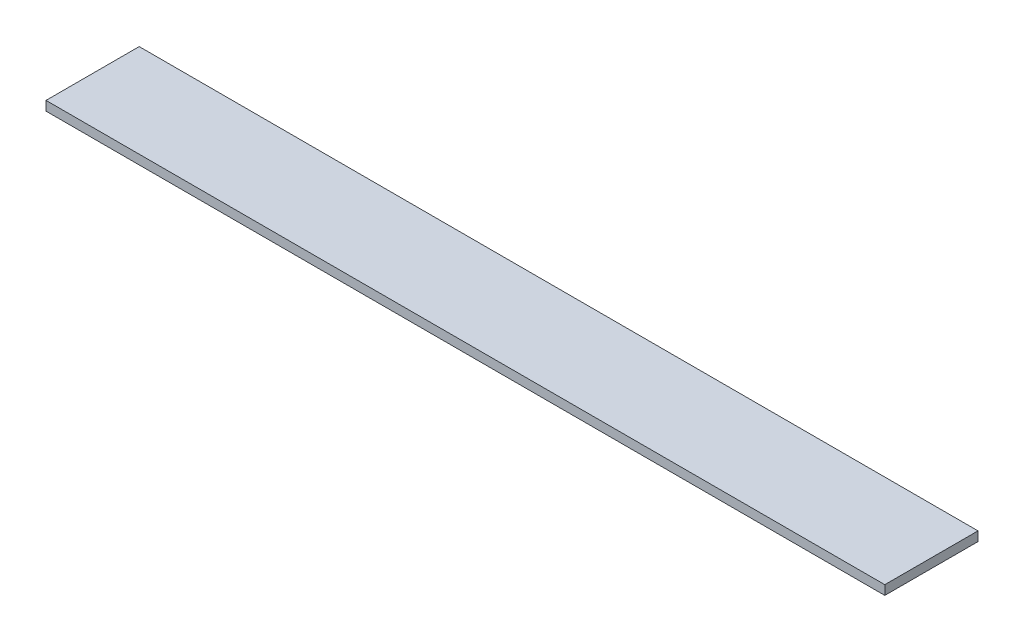
from build123d import *

# Parameters (mm, degrees)
ESQUISSE1_W      = 900
ESQUISSE1_H      = 100
EXTRUSION1_DEPTH = 10


with BuildPart() as part:
    # Esquisse1 → Extrusion1 (new body)
    with BuildSketch(Plane(origin=(0, 0, 0), x_dir=(1, 0, 0), z_dir=(0, 1, 0))):
        with Locations((450, 50)):
            Rectangle(ESQUISSE1_W, ESQUISSE1_H)
    extrude(amount=EXTRUSION1_DEPTH)


solid = part.part
